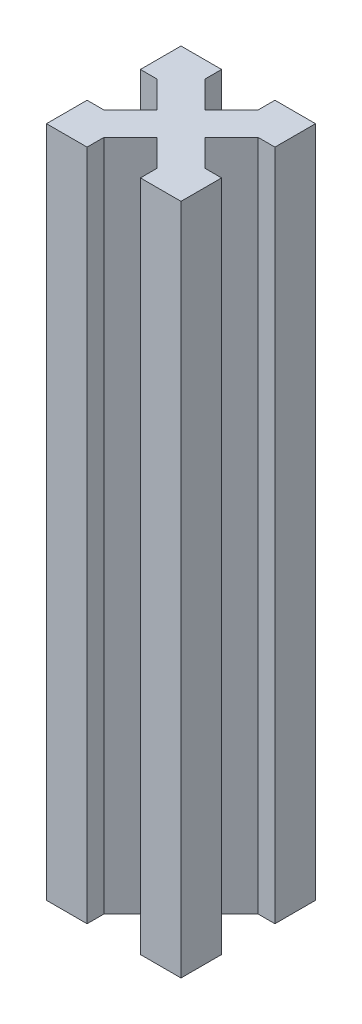
from build123d import *

# Parameters (mm, degrees)
BOSS_EXTRU_1_DEPTH = 100


with BuildPart() as part:
    # Esquisse1 → Boss.-Extru.1 (new body)
    with BuildSketch(Plane(origin=(0, 0, 0), x_dir=(1, 0, 0), z_dir=(0, 1, 0))):
        Polygon((-3.535533906, 0), (-6.035533906, 2.5), (-6.035533906, 0), align=None)
        Polygon((0, 3.535533906), (-2.5, 6.035533906), (-2.5, 2.5), (-6.035533906, 2.5), (-3.535533906, 0), (0, 0), align=None)
        Polygon((0, 6.035533906), (-2.5, 6.035533906), (0, 3.535533906), align=None)
        Polygon((-2.5, 2.5), (-2.5, 6.035533906), (-6.464466094, 10), (-10, 6.464466094), (-6.035533906, 2.5), align=None)
        Polygon((-13.964466094, 0), (-13.964466094, 2.5), (-16.464466094, 0), align=None)
        Polygon((-17.5, 2.5), (-17.5, 6.035533906), (-20, 3.535533906), (-20, 0), (-16.464466094, 0), (-13.964466094, 2.5), align=None)
        Polygon((-20, 3.535533906), (-17.5, 6.035533906), (-20, 6.035533906), align=None)
        Polygon((-10, 6.464466094), (-13.535533906, 10), (-17.5, 6.035533906), (-17.5, 2.5), (-13.964466094, 2.5), align=None)
        Polygon((-6.464466094, 10), (-10, 13.535533906), (-13.535533906, 10), (-10, 6.464466094), align=None)
        Polygon((-2.5, 13.964466094), (-2.5, 17.5), (-6.035533906, 17.5), (-10, 13.535533906), (-6.464466094, 10), align=None)
        Polygon((-6.035533906, 17.5), (-2.5, 17.5), (-2.5, 13.964466094), (0, 16.464466094), (0, 20), (-3.535533906, 20), align=None)
        Polygon((0, 16.464466094), (-2.5, 13.964466094), (0, 13.964466094), align=None)
        Polygon((-6.035533906, 20), (-6.035533906, 17.5), (-3.535533906, 20), align=None)
        Polygon((-16.464466094, 20), (-13.964466094, 17.5), (-13.964466094, 20), align=None)
        Polygon((-17.5, 17.5), (-13.964466094, 17.5), (-16.464466094, 20), (-20, 20), (-20, 16.464466094), (-17.5, 13.964466094), align=None)
        Polygon((-20, 13.964466094), (-17.5, 13.964466094), (-20, 16.464466094), align=None)
        Polygon((-10, 13.535533906), (-13.964466094, 17.5), (-17.5, 17.5), (-17.5, 13.964466094), (-13.535533906, 10), align=None)
    extrude(amount=BOSS_EXTRU_1_DEPTH)


solid = part.part
